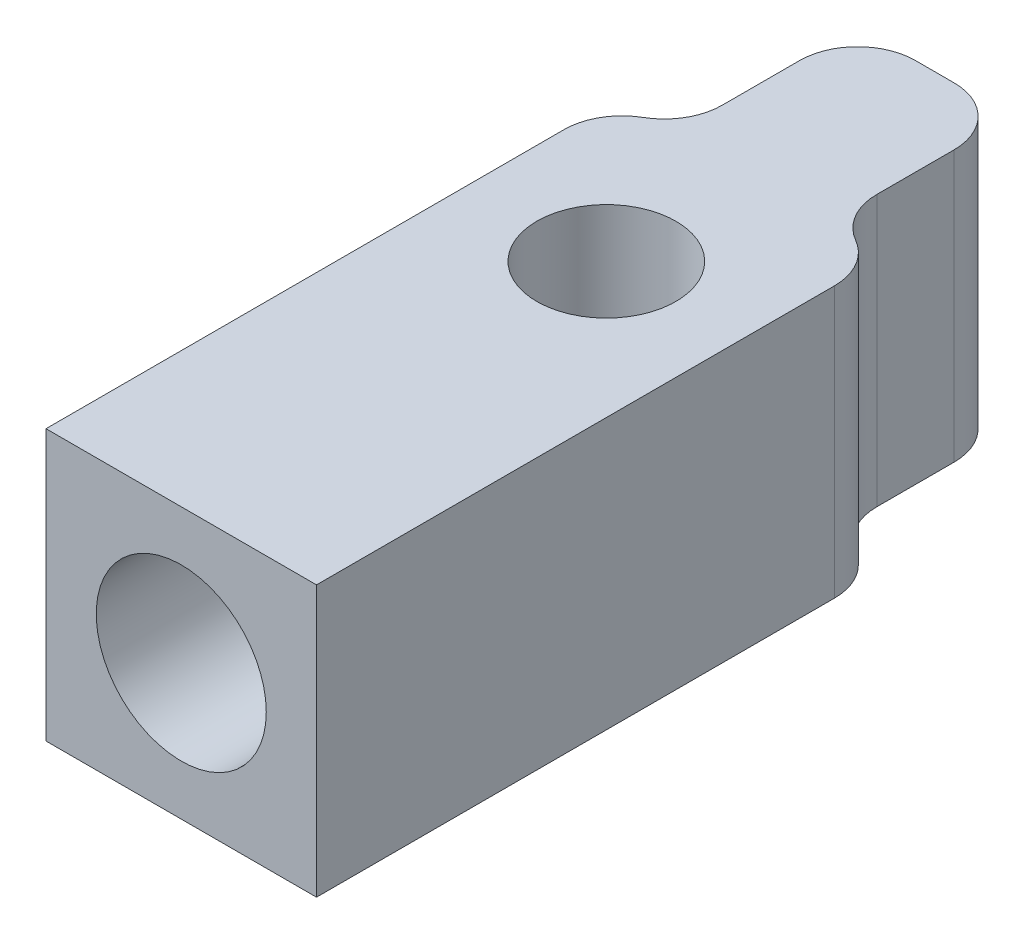
from build123d import *

# Parameters (mm, degrees)
SKETCH1_W           = 7
SKETCH1_H           = 19.5
BOSS_EXTRUDE1_DEPTH = 7
CUT_EXTRUDE1_DEPTH  = 8
CUT_EXTRUDE2_DEPTH  = 8
FILLET1_R           = 1.5
CUT_EXTRUDE3_REACH  = 9
SKETCH4_R           = 1.8
SKETCH5_R           = 2.2
CUT_EXTRUDE4_DEPTH  = 7


with BuildPart() as part:
    # Sketch1 → Boss-Extrude1 (new body)
    with BuildSketch(Plane(origin=(-3.5, 0, 0), x_dir=(0, -1, 0), z_dir=(-1, 0, 0))):
        with Locations((-5, 1.25)):
            Rectangle(SKETCH1_W, SKETCH1_H)
    extrude(amount=-BOSS_EXTRUDE1_DEPTH)

    # Sketch2 → Cut-Extrude1 (cut, through all)
    with BuildSketch(Plane(origin=(0, 8.5, 0), x_dir=(-1, 0, 0), z_dir=(0, 1, 0))):
        with BuildLine():
            Line((-3.5, -2.401923806), (-3.5, -8.5))
            Line((-3.5, -8.5), (-2.00000003, -8.5))
            Line((-2.00000003, -8.5), (-2.00000003, -5))
            ThreePointArc((-2.00000003, -5), (-2.20096192, -4.250000007), (-2.750000015, -3.700961903))
            ThreePointArc((-2.750000015, -3.700961903), (-3.29903811, -3.151923798), (-3.5, -2.401923806))
        make_face()
    extrude(amount=-CUT_EXTRUDE1_DEPTH, mode=Mode.SUBTRACT)

    # Sketch3 → Cut-Extrude2 (cut, through all)
    with BuildSketch(Plane(origin=(0, 8.5, 0), x_dir=(-1, 0, 0), z_dir=(0, 1, 0))):
        with BuildLine():
            Line((1.99999997, -5), (1.99999997, -8.5))
            Line((1.99999997, -8.5), (3.5, -8.5))
            Line((3.5, -8.5), (3.5, -2.401923771))
            ThreePointArc((3.5, -2.401923771), (3.299038101, -3.151923779), (2.749999985, -3.700961886))
            ThreePointArc((2.749999985, -3.700961886), (2.200961869, -4.249999993), (1.99999997, -5))
        make_face()
    extrude(amount=-CUT_EXTRUDE2_DEPTH, mode=Mode.SUBTRACT)

    # Fillet1
    fillet1_edges = [part.edges().sort_by_distance(p)[0] for p in [
        (2.00000003, 5, -8.5),
        (-1.99999997, 5, -8.5),
    ]]
    fillet(fillet1_edges, radius=FILLET1_R)

    # Sketch4 → Cut-Extrude3 (cut, up to next)
    with BuildSketch(Plane(origin=(0, 8.5, 0), x_dir=(1, 0, 0), z_dir=(0, 1, 0)), mode=Mode.PRIVATE) as cut_extrude3_sk1:
        Circle(SKETCH4_R)
    cut_extrude3_tool1 = extrude(cut_extrude3_sk1.sketch, amount=-CUT_EXTRUDE3_REACH, mode=Mode.PRIVATE) & part.part
    add(cut_extrude3_tool1.solids().sort_by_distance((0, 8.5, 0))[0], mode=Mode.SUBTRACT)

    # Sketch5 → Cut-Extrude4 (cut)
    with BuildSketch(Plane.XY.offset(11)):
        with Locations((0, 5)):
            Circle(SKETCH5_R)
    extrude(amount=-CUT_EXTRUDE4_DEPTH, mode=Mode.SUBTRACT)


solid = part.part
